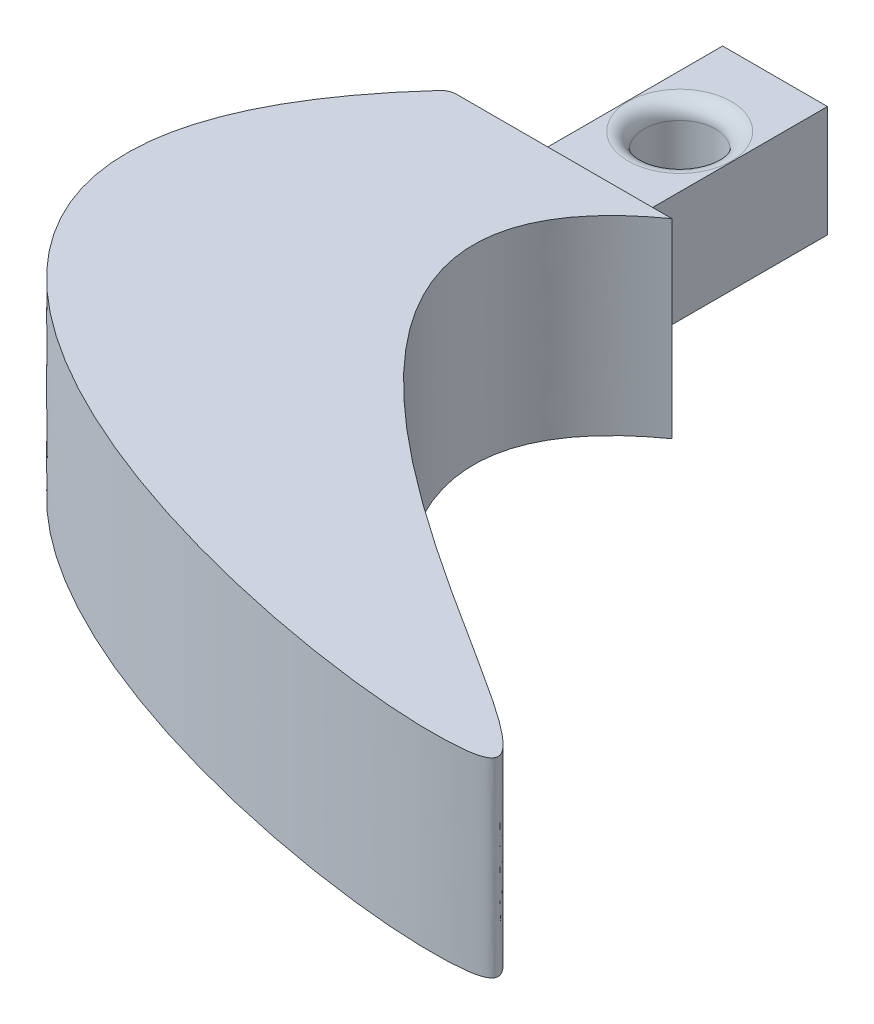
from build123d import *

# Parameters (mm, degrees)
SKETCH_1_W          = 7
SKETCH_1_H          = 7
EXTRUDE_1_DEPTH     = 14
EXTRUDE_2_DEPTH     = 6
SKETCH_15_R         = 2.25
CUT_EXTRUDE_2_DEPTH = 6
FILLET_3_R          = 1
SKETCH_16_W         = 0.2
SKETCH_16_H         = 14
CUT_EXTRUDE_3_DEPTH = 10
SKETCH_17_R         = 2.25
CUT_EXTRUDE_4_DEPTH = 10
FILLET_4_R          = 1


with BuildPart() as part:
    # 草图1 → 凸台-拉伸1 (new body)
    with BuildSketch(Plane.XY):
        with Locations((-0.508182669, -0.492792772)):
            Rectangle(SKETCH_1_W, SKETCH_1_H)
    extrude(amount=EXTRUDE_1_DEPTH)

    # 草图6 → 凸台-拉伸2 (add, symmetric)
    with BuildSketch(Plane(origin=(0, 0, 0), x_dir=(1, 0, 0), z_dir=(0, 1, 0))):
        with BuildLine():
            Line((-7, -14), (7, -14))
            add(Edge.make_bspline(
                [(-7, -14), (-31.495898122, -40.370243945), (23.118952024, -51.487081909), (36.035240151, -47.73153031), (-11.676861275, -27.319131635), (7, -14)],
                knots=[0, 0, 0, 0, 0.550644379, 0.609171062, 1, 1, 1, 1], degree=3))
        make_face()
    extrude(amount=EXTRUDE_2_DEPTH, both=True)

    # 草图15 → 切除-拉伸2 (cut, symmetric)
    with BuildSketch(Plane(origin=(0, 3.007207228, 0), x_dir=(1, 0, 0), z_dir=(0, 1, 0))):
        with Locations((-0.508182669, -6)):
            Circle(SKETCH_15_R)
    extrude(amount=CUT_EXTRUDE_2_DEPTH, both=True, mode=Mode.SUBTRACT)

    # 圆角3
    fillet_3_edges = [part.edges().sort_by_distance(p)[0] for p in [
        (-7, -3, 14),
    ]]
    fillet(fillet_3_edges, radius=FILLET_3_R)

    # 草图16 → 切除-拉伸3 (cut)
    with BuildSketch(Plane(origin=(0, 3.007207228, 0), x_dir=(1, 0, 0), z_dir=(0, 1, 0))):
        with Locations((-3.908182669, -7)):
            Rectangle(SKETCH_16_W, SKETCH_16_H)
        with Locations((2.891817331, -7)):
            Rectangle(SKETCH_16_W, SKETCH_16_H)
    extrude(amount=-CUT_EXTRUDE_3_DEPTH, mode=Mode.SUBTRACT)

    # 草图17 → 切除-拉伸4 (cut)
    with BuildSketch(Plane(origin=(0, -2.992792772, 0), x_dir=(1, 0, 0), z_dir=(0, 1, 0))):
        with Locations((-0.508182669, -6)):
            Circle(SKETCH_17_R)
    extrude(amount=-CUT_EXTRUDE_4_DEPTH, mode=Mode.SUBTRACT)

    # 圆角4
    fillet_4_edges = [part.edges().sort_by_distance(p)[0] for p in [
        (-2.758182669, 3.007207228, 6),
        (-2.758182669, -3.992792772, 6),
    ]]
    fillet(fillet_4_edges, radius=FILLET_4_R)


solid = part.part
